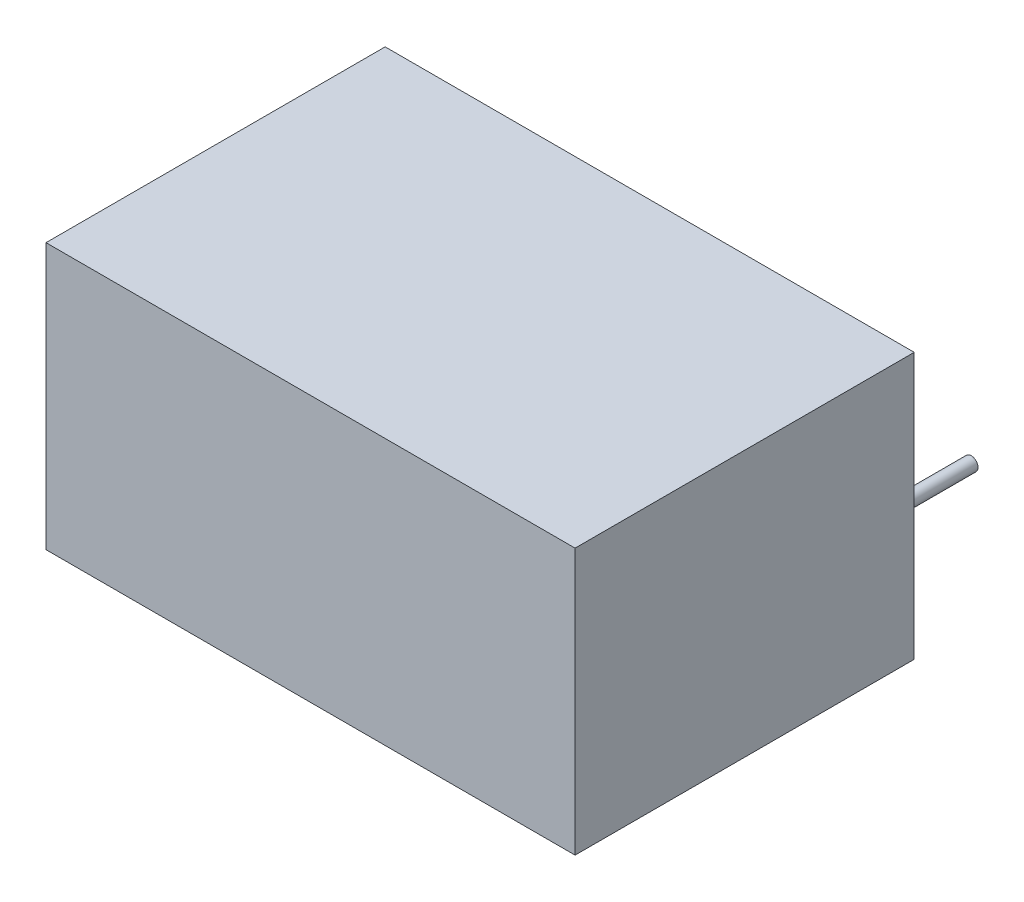
from build123d import *

# Parameters (mm, degrees)
SKETCH1_W           = 19.5
SKETCH1_H           = 9.8
BOSS_EXTRUDE1_DEPTH = 12.5
SKETCH2_R           = 0.25
BOSS_EXTRUDE2_DEPTH = 4.1
SKETCH3_W           = 0.455897436
SKETCH3_H           = 5.08
CUT_EXTRUDE1_DEPTH  = 0.0254


with BuildPart() as part:
    # Sketch1 → Boss-Extrude1 (new body)
    with BuildSketch(Plane.XY):
        Rectangle(SKETCH1_W, SKETCH1_H)
    extrude(amount=BOSS_EXTRUDE1_DEPTH)

    # Sketch2 → Boss-Extrude2 (add)
    with BuildSketch(Plane(origin=(0, 0, 0), x_dir=(-1, 0, 0), z_dir=(0, 0, -1))):
        with Locations((-7.75, -1.7)):
            Circle(SKETCH2_R)
        with Locations((-5.21, -1.7)):
            Circle(SKETCH2_R)
        with Locations((2.41, -1.7)):
            Circle(SKETCH2_R)
        with Locations((7.49, -1.7)):
            Circle(SKETCH2_R)
    extrude(amount=BOSS_EXTRUDE2_DEPTH)

    # Sketch3 → Cut-Extrude1 (cut)
    with BuildSketch(Plane.XZ.offset(4.9)):
        with BuildLine():
            Line((-0.670988461, 7.779755364), (-1.069898718, 7.474466902))
            add(Edge.make_bspline(
                [(-1.069898718, 7.474466902), (-1.098355264, 7.508380939), (-1.154884701, 7.575751776), (-1.245830058, 7.670355229), (-1.340610728, 7.758987095), (-1.439190481, 7.842069594), (-1.543343718, 7.916697357), (-1.650547391, 7.986759415), (-1.76259484, 8.049559446), (-1.917537357, 8.125705723), (-2.120226234, 8.205165857), (-2.375379886, 8.271791118), (-2.641733138, 8.314203567), (-2.823448511, 8.318797109), (-2.915876282, 8.321133569)],
                knots=[0, 0, 0, 0, 0.000132784, 0.000263778, 0.000393372, 0.000521973, 0.00065021, 0.000777511, 0.000906007, 0.001035257, 0.001295287, 0.001557426, 0.001825123, 0.002102233, 0.002102233, 0.002102233, 0.002102233], degree=3))
            add(Edge.make_bspline(
                [(-2.915876282, 8.321133569), (-2.966797185, 8.320547246), (-3.068166397, 8.319380043), (-3.218604753, 8.303981655), (-3.366233981, 8.282339099), (-3.510958052, 8.250225772), (-3.652592746, 8.209625514), (-3.792064004, 8.161110913), (-3.927352532, 8.101087317), (-4.06032986, 8.034745043), (-4.187735115, 7.959811494), (-4.308283585, 7.878076686), (-4.421535607, 7.790455255), (-4.527580769, 7.696618792), (-4.626527483, 7.596989889), (-4.71765878, 7.490506788), (-4.800659318, 7.377509919), (-4.877174314, 7.259489316), (-4.945700225, 7.13678875), (-5.003075021, 7.008954076), (-5.053882455, 6.878174407), (-5.094085928, 6.74297215), (-5.125907798, 6.60429865), (-5.14786452, 6.461781735), (-5.163087787, 6.315719137), (-5.164249187, 6.216718192), (-5.164834615, 6.166814659)],
                knots=[0, 0, 0, 0, 0.000152698, 0.00030398, 0.000453225, 0.000600137, 0.000748306, 0.00089507, 0.001042725, 0.001191997, 0.001340696, 0.001485772, 0.001628664, 0.001769965, 0.001910283, 0.002049579, 0.002190015, 0.002330584, 0.002471334, 0.002611138, 0.002750613, 0.002891946, 0.003033893, 0.003177104, 0.003324334, 0.00347398, 0.00347398, 0.00347398, 0.00347398], degree=3))
            add(Edge.make_bspline(
                [(-5.164834615, 6.166814659), (-5.163003175, 6.091730343), (-5.159407385, 5.944312248), (-5.127405803, 5.728382334), (-5.078775556, 5.521523756), (-5.005891233, 5.325029585), (-4.916020154, 5.136476882), (-4.802459495, 4.959055918), (-4.670936064, 4.79008559), (-4.519589192, 4.633559254), (-4.353537322, 4.490573619), (-4.175377496, 4.364661346), (-3.985553444, 4.25970146), (-3.786161078, 4.172360371), (-3.575666032, 4.105222035), (-3.354446834, 4.057957536), (-3.122984623, 4.027126028), (-2.964823323, 4.024174275), (-2.884329807, 4.022672031)],
                knots=[0, 0, 0, 0, 0.000225126, 0.000442005, 0.000653527, 0.000861492, 0.00106949, 0.001278973, 0.001492107, 0.001710899, 0.001930992, 0.002148664, 0.002364137, 0.002580608, 0.002800736, 0.003025687, 0.003258566, 0.003499917, 0.003499917, 0.003499917, 0.003499917], degree=3))
            add(Edge.make_bspline(
                [(-2.884329807, 4.022672031), (-2.795643619, 4.025123174), (-2.621087984, 4.02994761), (-2.365102392, 4.070818749), (-2.120049337, 4.137087955), (-1.88591564, 4.229831225), (-1.663361354, 4.350394557), (-1.452038201, 4.496550334), (-1.251767808, 4.669688828), (-1.131340918, 4.801889483), (-1.069898718, 4.869338697)],
                knots=[0, 0, 0, 0, 0.00026593, 0.000523414, 0.000775462, 0.001026224, 0.001277102, 0.001533128, 0.001795719, 0.002069251, 0.002069251, 0.002069251, 0.002069251], degree=3))
            Line((-1.069898718, 4.869338697), (-0.670988461, 4.56710312))
            add(Edge.make_bspline(
                [(-0.670988461, 4.56710312), (-0.703091318, 4.525681596), (-0.76714326, 4.443036954), (-0.870859468, 4.326528301), (-0.980119088, 4.216939586), (-1.095733661, 4.115154353), (-1.216373199, 4.019135872), (-1.344203869, 3.931612071), (-1.477545208, 3.851361302), (-1.615945423, 3.777879937), (-1.759257467, 3.712685761), (-1.907309618, 3.656872864), (-2.05946371, 3.608794453), (-2.2157267, 3.569240213), (-2.376422713, 3.538366754), (-2.540971858, 3.517727912), (-2.709729277, 3.503588219), (-2.823581397, 3.502299473), (-2.881276923, 3.50164639)],
                knots=[0, 0, 0, 0, 0.00015718, 0.000313607, 0.000467595, 0.000621149, 0.00077547, 0.000929872, 0.001085545, 0.001242141, 0.001399716, 0.00155753, 0.001716522, 0.001878184, 0.002040842, 0.002207077, 0.002375506, 0.002548551, 0.002548551, 0.002548551, 0.002548551], degree=3))
            add(Edge.make_bspline(
                [(-2.881276923, 3.50164639), (-2.935914017, 3.502026653), (-3.043952104, 3.502778577), (-3.203462292, 3.514959209), (-3.358750026, 3.531577684), (-3.509371483, 3.556600503), (-3.656148613, 3.586128859), (-3.797750833, 3.62571114), (-3.935571538, 3.670051073), (-4.069057015, 3.722164597), (-4.198320808, 3.780970942), (-4.322945997, 3.847434119), (-4.442875265, 3.920995225), (-4.559287704, 4.000032783), (-4.670463626, 4.087085553), (-4.777366457, 4.180944554), (-4.880595651, 4.281293438), (-4.944462405, 4.353654196), (-4.976573397, 4.390035813)],
                knots=[0, 0, 0, 0, 0.000163867, 0.000324026, 0.00047967, 0.000632246, 0.000781931, 0.000928572, 0.001073064, 0.00121612, 0.001358198, 0.00149887, 0.001639539, 0.001780104, 0.001920765, 0.002062829, 0.002206751, 0.002352282, 0.002352282, 0.002352282, 0.002352282], degree=3))
            add(Edge.make_bspline(
                [(-4.976573397, 4.390035813), (-5.028005703, 4.453232738), (-5.130249377, 4.578863621), (-5.26106037, 4.782478702), (-5.373034535, 4.995066845), (-5.463568729, 5.217744913), (-5.534344353, 5.450013235), (-5.583375345, 5.691988896), (-5.615236531, 5.94344591), (-5.618880036, 6.114477591), (-5.620732051, 6.201414018)],
                knots=[0, 0, 0, 0, 0.000244284, 0.000485618, 0.000724588, 0.000964206, 0.001205644, 0.001451922, 0.001704114, 0.001964825, 0.001964825, 0.001964825, 0.001964825], degree=3))
            add(Edge.make_bspline(
                [(-5.620732051, 6.201414018), (-5.618474799, 6.292789362), (-5.614033795, 6.472564647), (-5.576302755, 6.736396556), (-5.51560576, 6.989164872), (-5.429395418, 7.230397736), (-5.32009508, 7.461363971), (-5.185073595, 7.680299205), (-5.025899571, 7.888603589), (-4.843821387, 8.083116428), (-4.644152226, 8.260973545), (-4.430329491, 8.41744655), (-4.202771693, 8.547665116), (-3.963985783, 8.656516689), (-3.712183708, 8.740183509), (-3.447902704, 8.798753278), (-3.171639364, 8.835208978), (-2.98315333, 8.839817565), (-2.887382692, 8.84215921)],
                knots=[0, 0, 0, 0, 0.000274014, 0.000539106, 0.00079777, 0.001052689, 0.001306228, 0.001562963, 0.001822874, 0.002091438, 0.002361023, 0.002624006, 0.002884781, 0.003146199, 0.003410077, 0.003679177, 0.003957245, 0.004244476, 0.004244476, 0.004244476, 0.004244476], degree=3))
            add(Edge.make_bspline(
                [(-2.887382692, 8.84215921), (-2.829014258, 8.841459421), (-2.713479822, 8.840074259), (-2.542570258, 8.826567058), (-2.376175109, 8.804050167), (-2.214179741, 8.7734017), (-2.055796058, 8.735363645), (-1.902234566, 8.68581144), (-1.752594186, 8.629152703), (-1.607818674, 8.563898701), (-1.468602652, 8.490649831), (-1.334989481, 8.410218012), (-1.208040486, 8.322702957), (-1.086862386, 8.228848977), (-0.973482286, 8.126670496), (-0.864681054, 8.018977986), (-0.764153546, 7.902669464), (-0.702100338, 7.820801731), (-0.670988461, 7.779755364)],
                knots=[0, 0, 0, 0, 0.000175079, 0.000346552, 0.000513929, 0.000678587, 0.000840991, 0.001002229, 0.001162308, 0.00132081, 0.001478305, 0.001633979, 0.001788381, 0.001940645, 0.002093438, 0.002245987, 0.002399636, 0.002554131, 0.002554131, 0.002554131, 0.002554131], degree=3))
        make_face()
        with BuildLine():
            Line((0.371062821, 8.7119028), (0.826960257, 8.7119028))
            Line((0.826960257, 8.7119028), (0.826960257, 5.668176838))
            add(Edge.make_bspline(
                [(0.826960257, 5.668176838), (0.826892411, 5.62509737), (0.826763663, 5.543346656), (0.827623654, 5.426988094), (0.830032109, 5.323541211), (0.831550535, 5.232607255), (0.834928493, 5.154603496), (0.837683373, 5.089107331), (0.841225666, 5.036428888), (0.845482877, 5.005686287), (0.847312821, 4.99247171)],
                knots=[0, 0, 0, 0, 0.000129239, 0.000245253, 0.000349071, 0.000439663, 0.000518079, 0.000583279, 0.000636352, 0.000676365, 0.000676365, 0.000676365, 0.000676365], degree=3))
            add(Edge.make_bspline(
                [(0.847312821, 4.99247171), (0.854827532, 4.944796979), (0.869433529, 4.852133818), (0.906657414, 4.72018694), (0.958643958, 4.601269281), (1.020247003, 4.491670036), (1.101429193, 4.394439765), (1.198680039, 4.304869708), (1.316503772, 4.226533489), (1.447510594, 4.154904311), (1.588713167, 4.097333277), (1.733001519, 4.053800051), (1.878206757, 4.027269534), (1.975417877, 4.024197529), (2.023691026, 4.022672031)],
                knots=[0, 0, 0, 0, 0.000144722, 0.000281289, 0.000409832, 0.000533406, 0.00065706, 0.000788148, 0.000928713, 0.001080343, 0.001235494, 0.00138521, 0.001531936, 0.001676668, 0.001676668, 0.001676668, 0.001676668], degree=3))
            add(Edge.make_bspline(
                [(2.023691026, 4.022672031), (2.065134741, 4.024230648), (2.147782802, 4.027338879), (2.270582993, 4.046586899), (2.390180865, 4.081276863), (2.507166994, 4.12603857), (2.616823852, 4.185180788), (2.719212619, 4.253500749), (2.810600272, 4.333635392), (2.893996452, 4.422318178), (2.966618587, 4.522379373), (3.029568701, 4.631640213), (3.081132051, 4.75174498), (3.106595224, 4.83615197), (3.119676603, 4.879514979)],
                knots=[0, 0, 0, 0, 0.000124355, 0.000247991, 0.000371699, 0.000497367, 0.000623014, 0.000744662, 0.000865858, 0.000986823, 0.001109151, 0.001235877, 0.001364421, 0.001500228, 0.001500228, 0.001500228, 0.001500228], degree=3))
            add(Edge.make_bspline(
                [(3.119676603, 4.879514979), (3.12403107, 4.897438053), (3.133734579, 4.937377884), (3.142801719, 5.004900214), (3.152245476, 5.084568205), (3.158798051, 5.176954265), (3.165186108, 5.28174882), (3.169007826, 5.399497788), (3.170774262, 5.529773605), (3.171300667, 5.620686971), (3.171575641, 5.668176838)],
                knots=[0, 0, 0, 0, 5.5299e-05, 0.000123229, 0.000204142, 0.000296005, 0.000400999, 0.000519114, 0.000649386, 0.000791858, 0.000791858, 0.000791858, 0.000791858], degree=3))
            Line((3.171575641, 5.668176838), (3.171575641, 8.7119028))
            Line((3.171575641, 8.7119028), (3.627473077, 8.7119028))
            Line((3.627473077, 8.7119028), (3.627473077, 5.643753761))
            add(Edge.make_bspline(
                [(3.627473077, 5.643753761), (3.62710424, 5.588456686), (3.626384431, 5.48054108), (3.620142451, 5.322405965), (3.610190006, 5.172396495), (3.596128438, 5.030492506), (3.577496445, 4.897201783), (3.556776982, 4.771356005), (3.530390688, 4.653858519), (3.499571923, 4.543793181), (3.464340602, 4.439021065), (3.418706021, 4.339585704), (3.367289889, 4.242464232), (3.306308622, 4.149125606), (3.237784672, 4.059156552), (3.160203376, 3.973102694), (3.076130593, 3.889588878), (2.984168718, 3.810757342), (2.88583367, 3.738463606), (2.78141796, 3.674894269), (2.671723677, 3.621157133), (2.557035963, 3.576923506), (2.437305874, 3.543664602), (2.312530392, 3.518881233), (2.182425506, 3.504799041), (2.093939662, 3.502706182), (2.049131731, 3.50164639)],
                knots=[0, 0, 0, 0, 0.000165886, 0.000323736, 0.000474689, 0.000616855, 0.000751417, 0.000878396, 0.00099937, 0.001112455, 0.001221232, 0.00133055, 0.001440274, 0.001550639, 0.001664618, 0.001779213, 0.001897944, 0.002019911, 0.002142238, 0.002263708, 0.002386132, 0.002508218, 0.002631926, 0.002758456, 0.002889489, 0.003023912, 0.003023912, 0.003023912, 0.003023912], degree=3))
            add(Edge.make_bspline(
                [(2.049131731, 3.50164639), (2.000263434, 3.50278542), (1.904384009, 3.505020195), (1.763104757, 3.517825786), (1.627665866, 3.541946198), (1.496636879, 3.572658345), (1.371801689, 3.615016455), (1.251487775, 3.664507448), (1.137755747, 3.7252893), (1.028760531, 3.792916282), (0.927414885, 3.8690069), (0.834382083, 3.951941781), (0.749508534, 4.040392386), (0.674224826, 4.135316345), (0.607283656, 4.235975394), (0.549618089, 4.342654291), (0.500105152, 4.455311733), (0.474550478, 4.533620949), (0.461631731, 4.57320889)],
                knots=[0, 0, 0, 0, 0.000146627, 0.000287681, 0.000425035, 0.000559057, 0.000690996, 0.000820078, 0.0009489, 0.001077371, 0.001204574, 0.00132855, 0.001450911, 0.001571854, 0.001691524, 0.001813104, 0.001935237, 0.002060102, 0.002060102, 0.002060102, 0.002060102], degree=3))
            add(Edge.make_bspline(
                [(0.461631731, 4.57320889), (0.454117456, 4.60025274), (0.437818825, 4.658911455), (0.420364965, 4.755992416), (0.405692355, 4.867774068), (0.391895716, 4.994264063), (0.383754714, 5.13556044), (0.376617403, 5.291601952), (0.371012539, 5.46257728), (0.371045592, 5.581673548), (0.371062821, 5.643753761)],
                knots=[0, 0, 0, 0, 8.4168e-05, 0.000182563, 0.000295538, 0.000422416, 0.000564162, 0.000720022, 0.000891059, 0.001077288, 0.001077288, 0.001077288, 0.001077288], degree=3))
            Line((0.371062821, 5.643753761), (0.371062821, 8.7119028))
        make_face()
        with Locations((5.157985898, 6.1719028)):
            Rectangle(SKETCH3_W, SKETCH3_H)
    extrude(amount=-CUT_EXTRUDE1_DEPTH, mode=Mode.SUBTRACT)


solid = part.part
